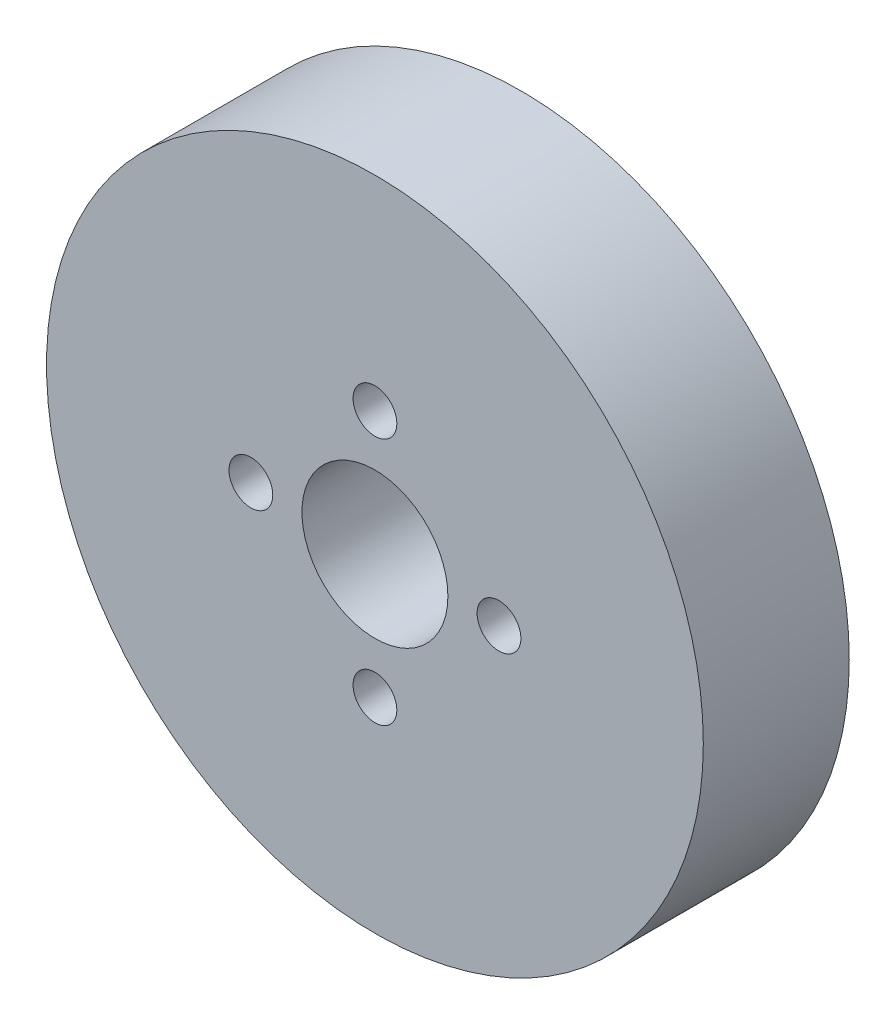
from build123d import *

# Parameters (mm, degrees)
ESQUISSE1_R        = 22.5
ESQUISSE1_R_2      = 5
BOSS_EXTRU_1_DEPTH = 10
D_GAGEMENT_M21_D   = 3


with BuildPart() as part:
    # Esquisse1 → Boss.-Extru.1 (new body)
    with BuildSketch(Plane.XY):
        Circle(ESQUISSE1_R)
        Circle(ESQUISSE1_R_2, mode=Mode.SUBTRACT)
    extrude(amount=BOSS_EXTRU_1_DEPTH)

    # Dégagement M21 (through all)
    with Locations(Plane.XY.offset(10)):
        with Locations((0, 8.5), (8.5, 0), (0, -8.5), (-8.5, 0), (0, 0)):
            Hole(D_GAGEMENT_M21_D / 2)


solid = part.part
